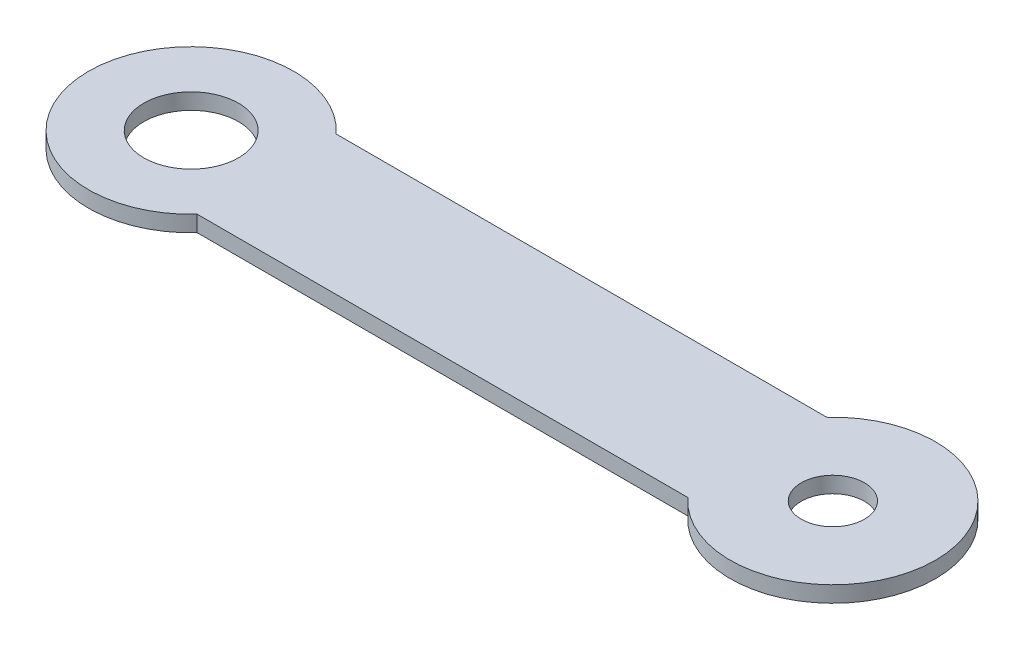
from build123d import *

# Parameters (mm, degrees)
BOSS_EXTRUDE1_DEPTH = 2.54
SKETCH2_R           = 7.5
SKETCH2_R_2         = 5
CUT_EXTRUDE1_DEPTH  = 2.54


with BuildPart() as part:
    # Sketch1 → Boss-Extrude1 (new body)
    with BuildSketch(Plane(origin=(0, 0, 0), x_dir=(1, 0, 0), z_dir=(0, 1, 0))):
        with BuildLine():
            Line((-38.836017724, 11), (38.836017598, 11))
            ThreePointArc((38.836017598, 11), (67.052288298, 0), (38.836017598, -11))
            Line((38.836017598, -11), (-38.836017724, -11))
            ThreePointArc((-38.836017724, -11), (-67.052288205, 0), (-38.836017724, 11))
        make_face()
    extrude(amount=BOSS_EXTRUDE1_DEPTH)

    # Sketch2 → Cut-Extrude1 (cut)
    with BuildSketch(Plane(origin=(0, 2.54, 0), x_dir=(1, 0, 0), z_dir=(0, 1, 0))):
        with Locations((-50.8, 0)):
            Circle(SKETCH2_R)
        with Locations((50.8, 0)):
            Circle(SKETCH2_R_2)
    extrude(amount=-CUT_EXTRUDE1_DEPTH, mode=Mode.SUBTRACT)


solid = part.part
